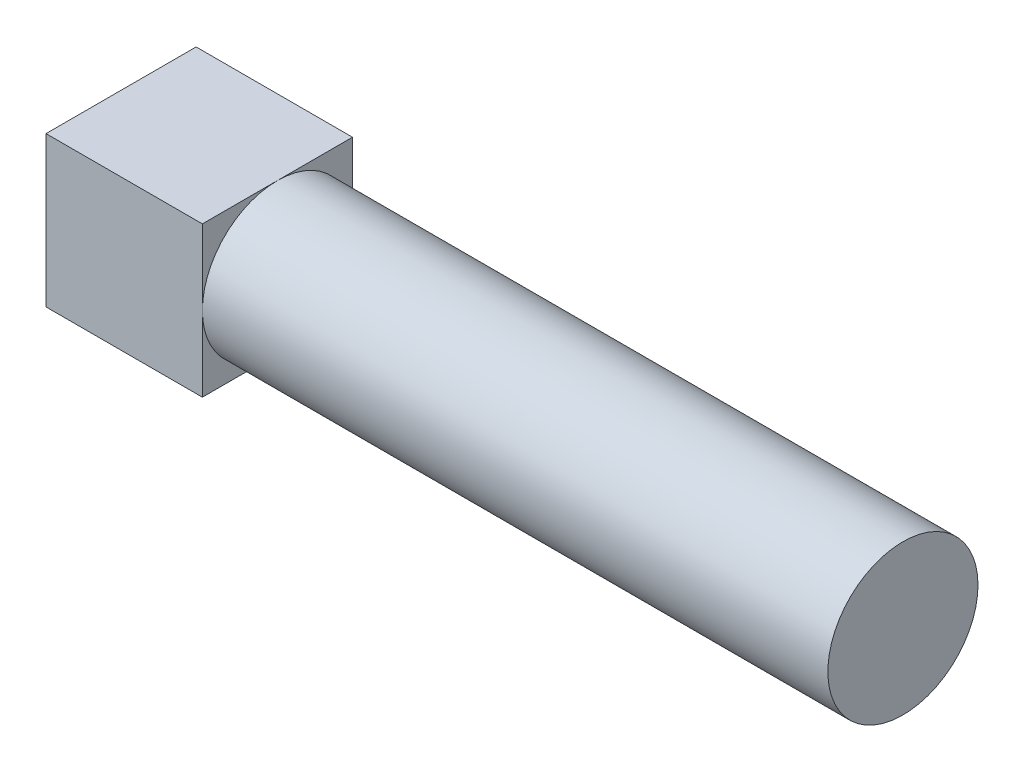
from build123d import *

# Parameters (mm, degrees)
SKETCH1_W           = 9.6
SKETCH1_H           = 9.6
BOSS_EXTRUDE1_DEPTH = 10
SKETCH2_R           = 4.8
BOSS_EXTRUDE2_DEPTH = 40


with BuildPart() as part:
    # Sketch1 → Boss-Extrude1 (new body)
    with BuildSketch(Plane(origin=(0, 0, 0), x_dir=(0, 0, -1), z_dir=(1, 0, 0))):
        Rectangle(SKETCH1_W, SKETCH1_H)
    extrude(amount=BOSS_EXTRUDE1_DEPTH)

    # Sketch2 → Boss-Extrude2 (add)
    with BuildSketch(Plane(origin=(10, 0, 0), x_dir=(0, 0, -1), z_dir=(1, 0, 0))):
        Circle(SKETCH2_R)
    extrude(amount=BOSS_EXTRUDE2_DEPTH)


solid = part.part
